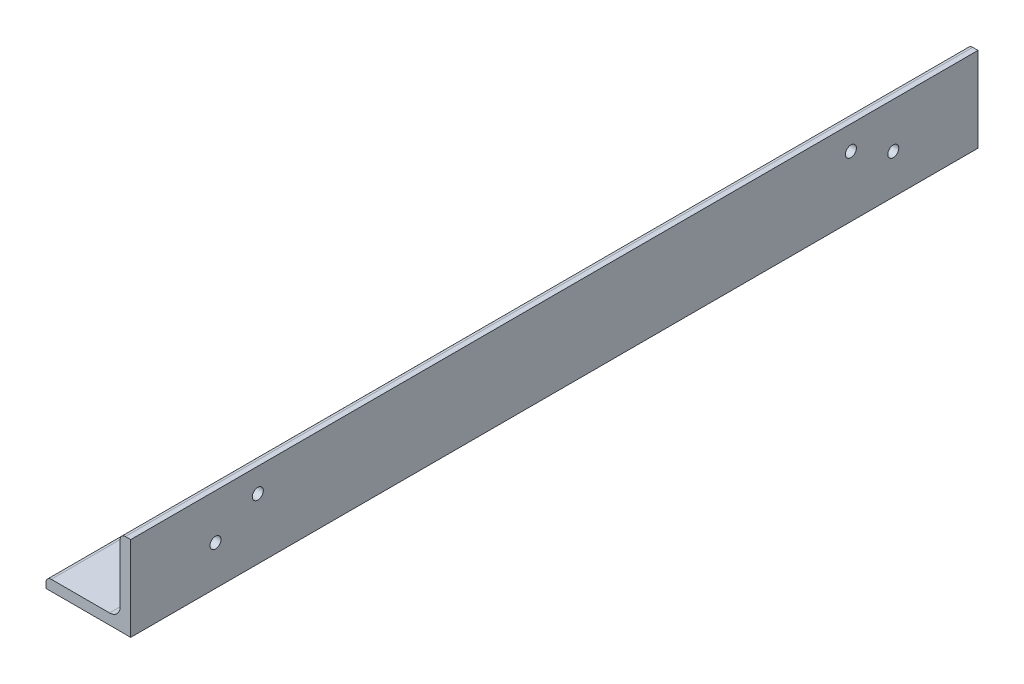
from build123d import *

# Parameters (mm, degrees)
BOSS_EXTRUDE1_DEPTH = 127
SKETCH4_R           = 1.651
CUT_EXTRUDE1_DEPTH  = 130.554006596
SKETCH5_R           = 1.651
CUT_EXTRUDE2_DEPTH  = 130.554006596
SKETCH4_5_R         = 1.651
SKETCH4_5_R_2       = 6.35
SKETCH4_5_R_3       = 6.323800798
SKETCH4_5_R_4       = 6.460876205
CUT_EXTRUDE3_DEPTH  = 130.554006596


with BuildPart() as part:
    # Sketch2 → Boss-Extrude1 (new, symmetric)
    with BuildSketch(Plane.XY):
        with BuildLine():
            Line((-12.7, -12.7), (12.7, -12.7))
            Line((12.7, -12.7), (12.7, 12.7))
            Line((12.7, 12.7), (11.1125, 12.7))
            ThreePointArc((11.1125, 12.7), (9.989967985, 12.235032015), (9.525, 11.1125))
            Line((9.525, 11.1125), (9.525, -6.35))
            ThreePointArc((9.525, -6.35), (8.59506403, -8.59506403), (6.35, -9.525))
            Line((6.35, -9.525), (-11.1125, -9.525))
            ThreePointArc((-11.1125, -9.525), (-12.235032015, -9.989967985), (-12.7, -11.1125))
            Line((-12.7, -11.1125), (-12.7, -12.7))
        make_face()
    extrude(amount=BOSS_EXTRUDE1_DEPTH, both=True)

    # Sketch4 → Cut-Extrude1 (cut, through all)
    with BuildSketch(Plane(origin=(0, -9.525, 0), x_dir=(1, 0, 0), z_dir=(0, 1, 0))):
        with Locations((-5.55625, 101.6)):
            Circle(SKETCH4_R)
        with Locations((0.79375, 88.907891862)):
            Circle(SKETCH4_R)
        with Locations((0.79375, -88.907891862)):
            Circle(SKETCH4_R)
        with Locations((-5.55625, -101.6)):
            Circle(SKETCH4_R)
    extrude(amount=-CUT_EXTRUDE1_DEPTH, mode=Mode.SUBTRACT)

    # Sketch5 → Cut-Extrude2 (cut, through all)
    with BuildSketch(Plane.ZY.offset(-9.525)):
        with Locations((-88.9, 5.55625)):
            Circle(SKETCH5_R)
        with Locations((-101.6, -0.79375)):
            Circle(SKETCH5_R)
        with Locations((88.9, 5.55625)):
            Circle(SKETCH5_R)
        with Locations((101.6, -0.79375)):
            Circle(SKETCH5_R)
    extrude(amount=-CUT_EXTRUDE2_DEPTH, mode=Mode.SUBTRACT)

    # Sketch4_5 → Cut-Extrude3 (cut, through all)
    with BuildSketch(Plane(origin=(0, -9.525, 0), x_dir=(1, 0, 0), z_dir=(0, 1, 0))):
        with Locations((-5.55625, 101.6)):
            Circle(SKETCH4_5_R)
        with Locations((0.79375, 88.907891862)):
            Circle(SKETCH4_5_R)
        with Locations((0.79375, -88.907891862)):
            Circle(SKETCH4_5_R)
        with Locations((-5.55625, -101.6)):
            Circle(SKETCH4_5_R)
        with Locations((-2.38125, 77.702134885)):
            Circle(SKETCH4_5_R_2)
        with Locations((-2.222550137, 58.755442455)):
            Circle(SKETCH4_5_R_3)
        with Locations((-2.061352022, 38.605678066)):
            Circle(SKETCH4_5_R_3)
        with Locations((-2.383748252, 20.551489173)):
            Circle(SKETCH4_5_R_3)
        with Locations((-2.38125, 0)):
            Circle(SKETCH4_5_R_4)
        with Locations((-2.061352022, -38.605678066)):
            Circle(SKETCH4_5_R_3)
        with Locations((-2.383748252, -20.551489173)):
            Circle(SKETCH4_5_R_3)
        with Locations((-2.222550137, -58.755442455)):
            Circle(SKETCH4_5_R_3)
        with Locations((-2.38125, -77.702134885)):
            Circle(SKETCH4_5_R_2)
    extrude(amount=-CUT_EXTRUDE3_DEPTH, mode=Mode.SUBTRACT)


solid = part.part
